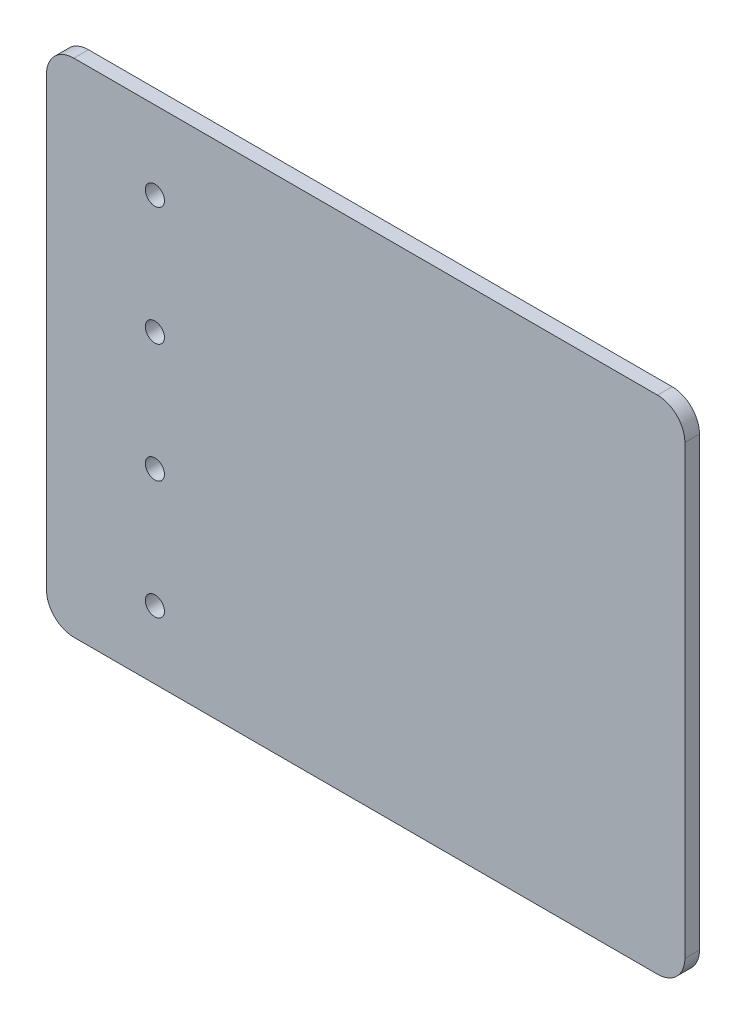
from build123d import *

# Parameters (mm, degrees)
ESQUISSE1_W        = 70
ESQUISSE1_H        = 55
BOSS_EXTRU_1_DEPTH = 1.6
CONG_1_R           = 3
SKETCH1_R          = 1.05
CUT_EXTRUDE1_DEPTH = 2.6


with BuildPart() as part:
    # Esquisse1 → Boss.-Extru.1 (new body)
    with BuildSketch(Plane.XY):
        Rectangle(ESQUISSE1_W, ESQUISSE1_H)
    extrude(amount=BOSS_EXTRU_1_DEPTH)

    # Congé1
    cong_1_edges = [part.edges().sort_by_distance(p)[0] for p in [
        (35, -27.5, 0.8),
        (-35, -27.5, 0.8),
        (-35, 27.5, 0.8),
        (35, 27.5, 0.8),
    ]]
    fillet(cong_1_edges, radius=CONG_1_R)

    # Sketch1 → Cut-Extrude1 (cut, through all)
    with BuildSketch(Plane(origin=(0, 0, 0), x_dir=(-1, 0, 0), z_dir=(0, 0, -1))):
        with Locations((23.118003478, -20.06669)):
            Circle(SKETCH1_R)
        with Locations((23.118003478, -7.06669)):
            Circle(SKETCH1_R)
        with Locations((23.118003478, 5.93331)):
            Circle(SKETCH1_R)
        with Locations((23.118003478, 18.93331)):
            Circle(SKETCH1_R)
    extrude(amount=-CUT_EXTRUDE1_DEPTH, mode=Mode.SUBTRACT)


solid = part.part
